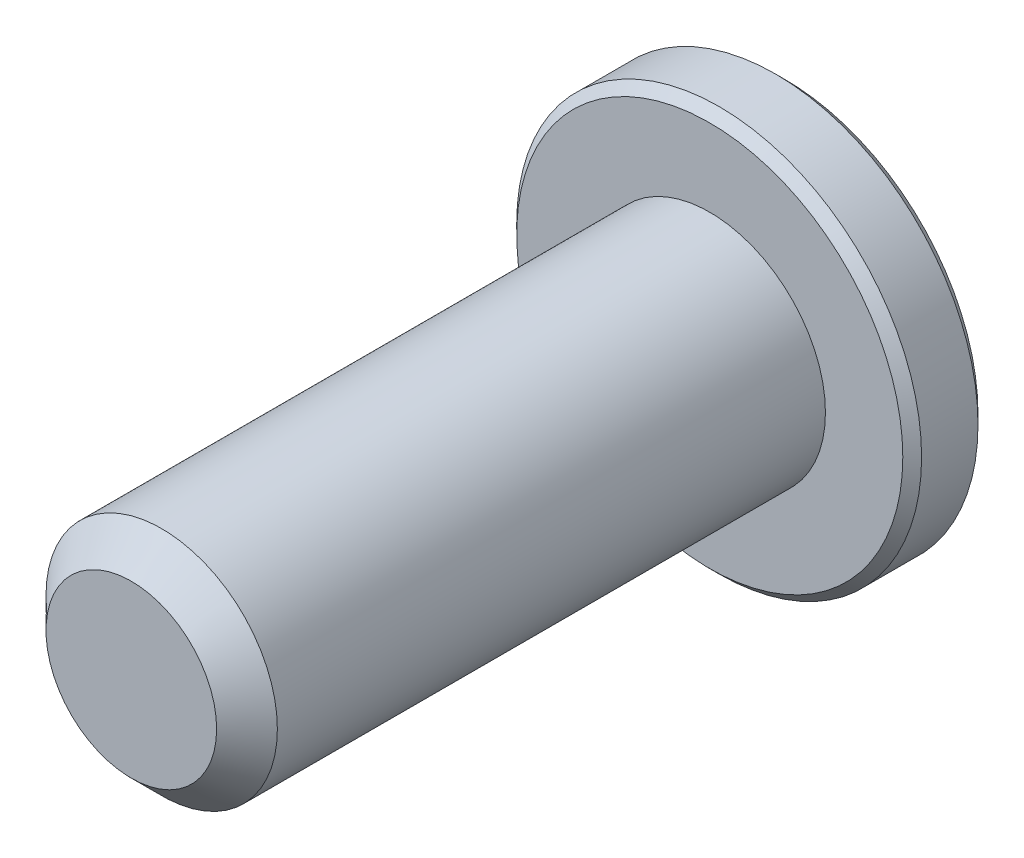
from build123d import *

# Parameters (mm, degrees)
EXTRUDE1_START     = -4.35
SKETCH1_R          = 2
EXTRUDE1_DEPTH     = 10
EXTRUDE2_START     = -5.65
SKETCH6_R          = 3.5
EXTRUDE2_DEPTH     = 1.3
CUT_EXTRUDE1_DEPTH = 0.975
SKETCH8_R          = 1.443375673
CUT_EXTRUDE2_DEPTH = 0.975
CUT_EXTRUDE2_TAPER = 45
CHAMFER1_SIZE      = 0.1625
CHAMFER2_SIZE      = 0.525


with BuildPart() as part:
    # Sketch1 → Extrude1 (new body)
    with BuildSketch(Plane.XY.offset(EXTRUDE1_START)):
        Circle(SKETCH1_R)
    extrude(amount=EXTRUDE1_DEPTH)

    # Sketch6 → Extrude2 (add)
    with BuildSketch(Plane.XY.offset(EXTRUDE2_START)):
        Circle(SKETCH6_R)
    extrude(amount=EXTRUDE2_DEPTH)

    # Sketch7 → Cut-Extrude1 (cut)
    with BuildSketch(Plane.XY.offset(-5.65)):
        Polygon((0, 1.443375673), (-1.25, 0.721687836), (-1.25, -0.721687836), (0, -1.443375673), (1.25, -0.721687836), (1.25, 0.721687836), align=None)
    extrude(amount=CUT_EXTRUDE1_DEPTH, mode=Mode.SUBTRACT)

    # Sketch8 → Cut-Extrude2 (cut)
    with BuildSketch(Plane.XY.offset(-5.65)):
        Circle(SKETCH8_R)
    extrude(amount=CUT_EXTRUDE2_DEPTH, taper=CUT_EXTRUDE2_TAPER, mode=Mode.SUBTRACT)

    # Chamfer1
    chamfer1_edges = [part.edges().sort_by_distance(p)[0] for p in [
        (-3.5, 0, -4.35),
        (-3.5, 0, -5.65),
    ]]
    chamfer(chamfer1_edges, length=CHAMFER1_SIZE)

    # Chamfer2
    chamfer2_edges = [part.edges().sort_by_distance(p)[0] for p in [
        (-2, 0, 5.65),
    ]]
    chamfer(chamfer2_edges, length=CHAMFER2_SIZE)


solid = part.part
